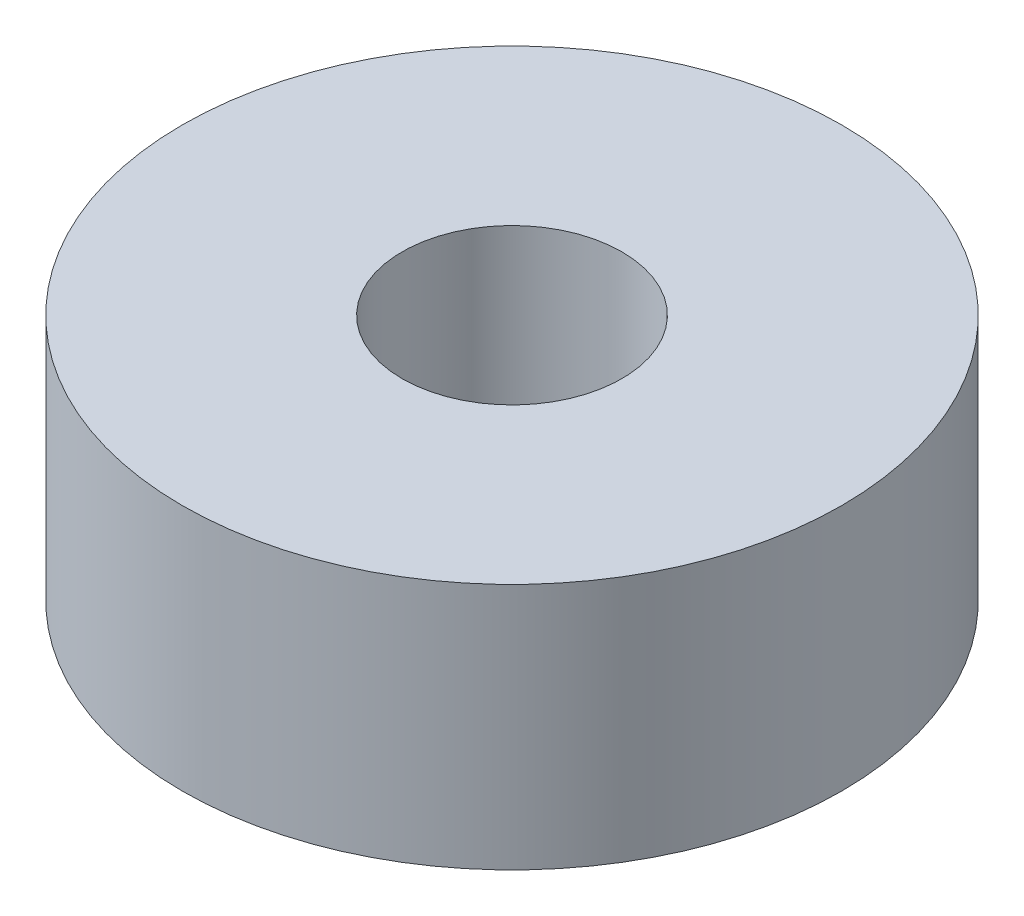
from build123d import *

# Parameters (mm, degrees)
CROQUIS1_R              = 12
CROQUIS1_R_2            = 4
SALIENTE_EXTRUIR1_DEPTH = 9


with BuildPart() as part:
    # Croquis1 → Saliente-Extruir1 (new body)
    with BuildSketch(Plane(origin=(0, 0, 0), x_dir=(1, 0, 0), z_dir=(0, 1, 0))):
        Circle(CROQUIS1_R)
        Circle(CROQUIS1_R_2, mode=Mode.SUBTRACT)
    extrude(amount=SALIENTE_EXTRUIR1_DEPTH)


solid = part.part
